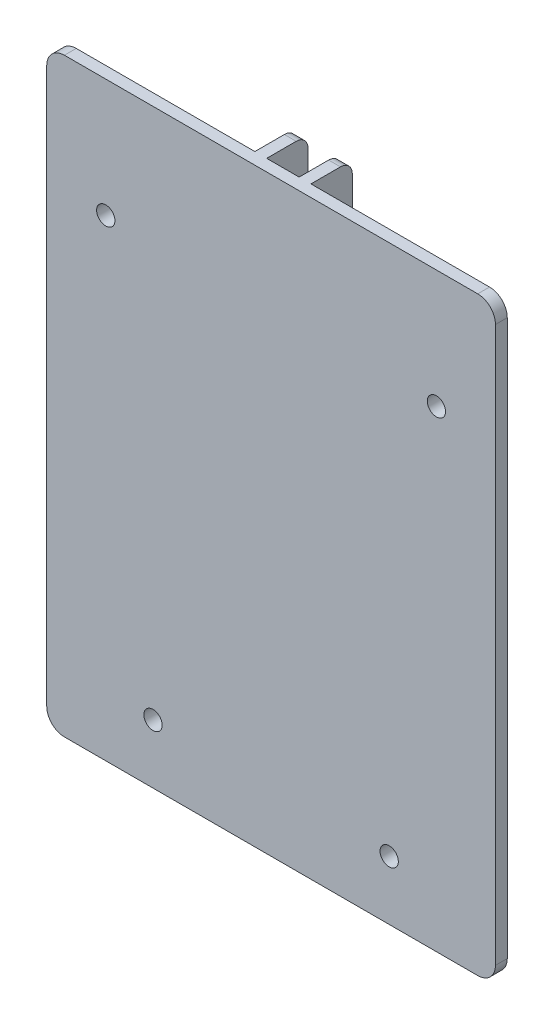
from build123d import *

# Parameters (mm, degrees)
ESQUISSE1_W                  = 76
ESQUISSE1_H                  = 100
BOSS_EXTRU_1_DEPTH           = 9
ESQUISSE2_W                  = 33.25
ESQUISSE2_H                  = 100
ESQUISSE2_W_2                = 5.5
ENL_V_MAT_EXTRU_1_DEPTH      = 7
ESQUISSE3_R                  = 1.55
ENL_V_MAT_EXTRU_2_DEPTH      = 43.75
CONG_1_R                     = 3
CONG_2_R                     = 2
ESQUISSE9_R                  = 3
BOSS_EXTRU_2_DEPTH           = 3
ESQUISSE5_R                  = 1.55
ENL_V_MAT_EXTRU_4_DEPTH      = 8
ENL_V_MAT_EXTRU_4_DEPTH_BACK = 3


with BuildPart() as part:
    # Esquisse1 → Boss.-Extru.1 (new body)
    with BuildSketch(Plane.XY):
        with Locations((38, 50)):
            Rectangle(ESQUISSE1_W, ESQUISSE1_H)
    extrude(amount=BOSS_EXTRU_1_DEPTH)

    # Esquisse2 → Enlèv. mat.-Extru.1 (cut)
    with BuildSketch(Plane(origin=(0, 0, 0), x_dir=(-1, 0, 0), z_dir=(0, 0, -1))):
        with Locations((-16.625, 50)):
            Rectangle(ESQUISSE2_W, ESQUISSE2_H)
        with Locations((-59.375, 50)):
            Rectangle(ESQUISSE2_W, ESQUISSE2_H)
        with Locations((-38, 50)):
            Rectangle(ESQUISSE2_W_2, ESQUISSE2_H)
    extrude(amount=-ENL_V_MAT_EXTRU_1_DEPTH, mode=Mode.SUBTRACT)

    # Esquisse3 → Enlèv. mat.-Extru.2 (cut, through all)
    with BuildSketch(Plane(origin=(42.75, 0, 0), x_dir=(0, 0, -1), z_dir=(1, 0, 0))):
        with Locations((-3.5, 20)):
            Circle(ESQUISSE3_R)
        with Locations((-3.5, 90)):
            Circle(ESQUISSE3_R)
    extrude(amount=-ENL_V_MAT_EXTRU_2_DEPTH, mode=Mode.SUBTRACT)

    # Congé1
    cong_1_edges = [part.edges().sort_by_distance(p)[0] for p in [
        (0, 100, 8),
        (76, 100, 8),
        (76, 0, 8),
        (0, 0, 8),
    ]]
    fillet(cong_1_edges, radius=CONG_1_R)

    # Congé2
    cong_2_edges = [part.edges().sort_by_distance(p)[0] for p in [
        (41.75, 100, 0),
        (34.25, 100, 0),
        (34.25, 0, 0),
        (41.75, 0, 0),
    ]]
    fillet(cong_2_edges, radius=CONG_2_R)

    # Esquisse9 → Boss.-Extru.2 (add)
    with BuildSketch(Plane(origin=(0, 0, 7), x_dir=(-1, 0, 0), z_dir=(0, 0, -1))):
        with Locations((-66, 80)):
            Circle(ESQUISSE9_R)
        with Locations((-10, 80)):
            Circle(ESQUISSE9_R)
        with Locations((-18, 10)):
            Circle(ESQUISSE9_R)
        with Locations((-58, 10)):
            Circle(ESQUISSE9_R)
    extrude(amount=BOSS_EXTRU_2_DEPTH)

    # Esquisse5 → Enlèv. mat.-Extru.4 (cut, two sides)
    with BuildSketch(Plane(origin=(0, 0, 7), x_dir=(-1, 0, 0), z_dir=(0, 0, -1))) as enl_v_mat_extru_4_sk:
        with Locations((-66, 80)):
            Circle(ESQUISSE5_R)
        with Locations((-58, 10)):
            Circle(ESQUISSE5_R)
        with Locations((-18, 10)):
            Circle(ESQUISSE5_R)
        with Locations((-10, 80)):
            Circle(ESQUISSE5_R)
    extrude(amount=ENL_V_MAT_EXTRU_4_DEPTH, mode=Mode.SUBTRACT)
    extrude(enl_v_mat_extru_4_sk.sketch, amount=-ENL_V_MAT_EXTRU_4_DEPTH_BACK, mode=Mode.SUBTRACT)


solid = part.part
